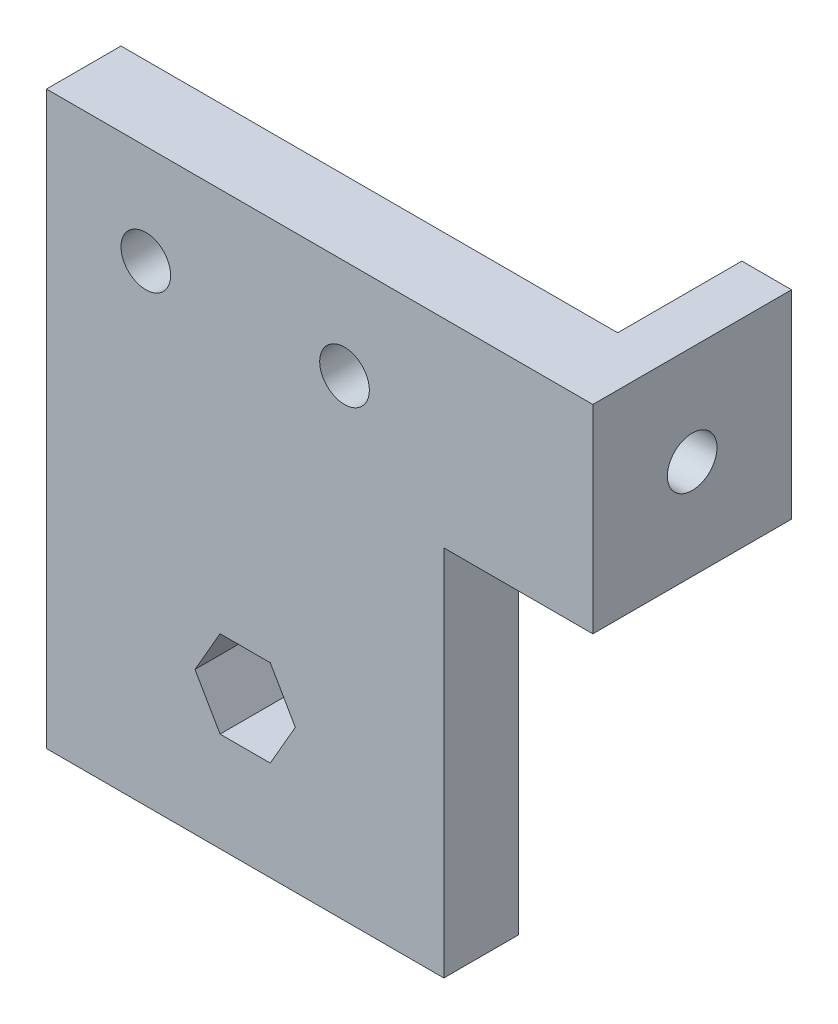
from build123d import *

# Parameters (mm, degrees)
SKETCH2_R      = 3.175
EXTRUDE1_DEPTH = 9.525
SKETCH3_W      = 25.4
SKETCH3_H      = 25.4
SKETCH3_R      = 3.175
EXTRUDE2_DEPTH = 6.35
SKETCH4_R      = 5.207
EXTRUDE3_DEPTH = 12.7
FILLET1_R      = 2


with BuildPart() as part:
    # Sketch2 → Extrude1 (new body)
    with BuildSketch(Plane.XY):
        Polygon((0, 0), (50.8, 0), (50.8, 47.625), (63.5, 47.625), (63.5, 73.025), (50.8, 73.025), (0, 73.025), align=None)
        with Locations((12.7, 60.325)):
            Circle(SKETCH2_R, mode=Mode.SUBTRACT)
        with Locations((38.1, 60.325)):
            Circle(SKETCH2_R, mode=Mode.SUBTRACT)
        Polygon((31.815804866, 18.25625), (28.607902433, 23.8125), (22.192097567, 23.8125), (18.984195134, 18.25625), (22.192097567, 12.7), (28.607902433, 12.7), align=None, mode=Mode.SUBTRACT)
    extrude(amount=EXTRUDE1_DEPTH)

    # Sketch3 → Extrude2 (add)
    with BuildSketch(Plane(origin=(63.5, 0, 0), x_dir=(0, 0, -1), z_dir=(1, 0, 0))):
        with Locations((3.175, 60.325)):
            Rectangle(SKETCH3_W, SKETCH3_H)
        with Locations((3.175, 60.325)):
            Circle(SKETCH3_R, mode=Mode.SUBTRACT)
    extrude(amount=EXTRUDE2_DEPTH)

    # Sketch4 → Extrude3 (cut)
    with BuildSketch(Plane.ZY.offset(-63.5)):
        with Locations((-3.175, 60.325)):
            Circle(SKETCH4_R)
    extrude(amount=EXTRUDE3_DEPTH, mode=Mode.SUBTRACT)

    # Fillet1
    fillet1_edges = [part.edges().sort_by_distance(p)[0] for p in [
        (50.8, 60.325, 0),
    ]]
    fillet(fillet1_edges, radius=FILLET1_R)


solid = part.part
